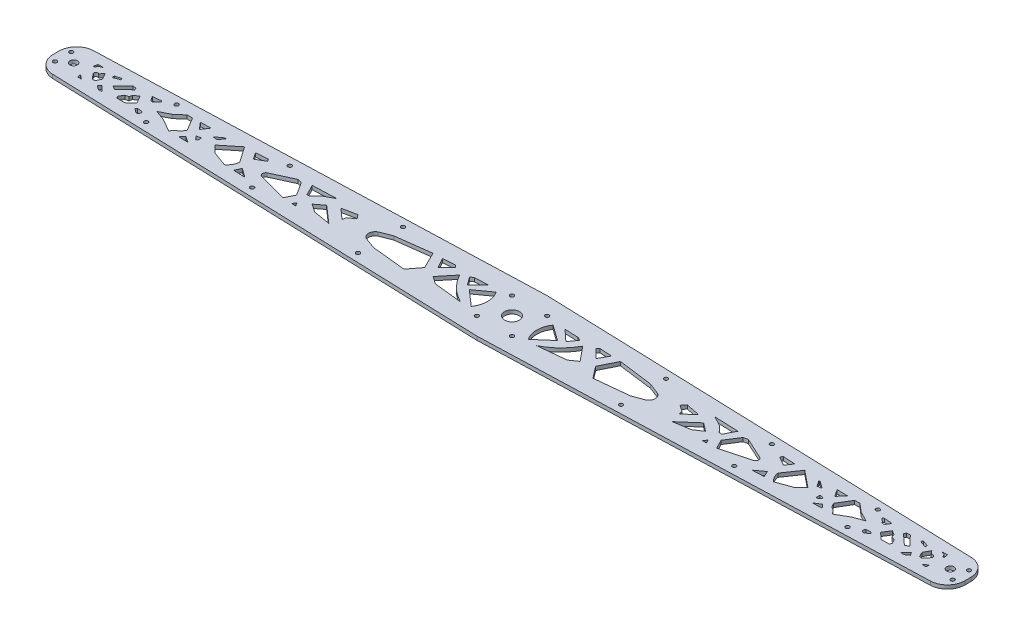
from build123d import *

# Parameters (mm, degrees)
BOSS_EXTRUDE1_DEPTH = 3.18
SKETCH3_R           = 6.35
SKETCH3_R_2         = 3.175
SKETCH3_R_3         = 1.65
CUT_EXTRUDE1_DEPTH  = 4.18
CUT_EXTRUDE3_DEPTH  = 4.18


with BuildPart() as part:
    # Sketch2 → Boss-Extrude1 (new body)
    with BuildSketch(Plane(origin=(0, 0, 0), x_dir=(1, 0, 0), z_dir=(0, 1, 0))):
        with BuildLine():
            Line((-375, 17.5), (0, 30))
            Line((0, 30), (375, 17.5))
            Line((375, 17.5), (375.499722453, 17.483342585))
            ThreePointArc((375.499722453, 17.483342585), (385.781832794, 12.920095592), (390, 2.49166898))
            Line((390, 2.49166898), (390, -2.49166898))
            ThreePointArc((390, -2.49166898), (385.781832794, -12.920095592), (375.499722453, -17.483342585))
            Line((375.499722453, -17.483342585), (375, -17.5))
            Line((375, -17.5), (0, -30))
            Line((0, -30), (-375, -17.5))
            Line((-375, -17.5), (-375.499722453, -17.483342585))
            ThreePointArc((-375.499722453, -17.483342585), (-385.781832794, -12.920095592), (-390, -2.49166898))
            Line((-390, -2.49166898), (-390, 2.49166898))
            ThreePointArc((-390, 2.49166898), (-385.781832794, 12.920095592), (-375.499722453, 17.483342585))
            Line((-375.499722453, 17.483342585), (-375, 17.5))
        make_face()
    extrude(amount=BOSS_EXTRUDE1_DEPTH)

    # Sketch3 → Cut-Extrude1 (cut, through all)
    with BuildSketch(Plane(origin=(0, 3.18, 0), x_dir=(1, 0, 0), z_dir=(0, 1, 0))):
        Circle(SKETCH3_R)
        with Locations((-375, 0)):
            Circle(SKETCH3_R_2)
        with Locations((-206.25, 16.125)):
            Circle(SKETCH3_R_3)
        with Locations((-112.5, -19.25)):
            Circle(SKETCH3_R_3)
        with Locations((375, 0)):
            Circle(SKETCH3_R_2)
        with Locations((-112.5, 19.25)):
            Circle(SKETCH3_R_3)
        with Locations((-206.25, -16.125)):
            Circle(SKETCH3_R_3)
        with Locations((112.5, -19.25)):
            Circle(SKETCH3_R_3)
        with Locations((112.5, 19.25)):
            Circle(SKETCH3_R_3)
        with Locations((206.25, -16.125)):
            Circle(SKETCH3_R_3)
        with Locations((206.25, 16.125)):
            Circle(SKETCH3_R_3)
        with Locations((-384, 7)):
            Circle(SKETCH3_R_3)
        with Locations((-384, -7)):
            Circle(SKETCH3_R_3)
        with Locations((384, -7)):
            Circle(SKETCH3_R_3)
        with Locations((384, 7)):
            Circle(SKETCH3_R_3)
        with Locations((-15, 15)):
            Circle(SKETCH3_R_3)
        with Locations((-15, -15)):
            Circle(SKETCH3_R_3)
        with Locations((15, -15)):
            Circle(SKETCH3_R_3)
        with Locations((15, 15)):
            Circle(SKETCH3_R_3)
        with Locations((-300, 13)):
            Circle(SKETCH3_R_3)
        with Locations((-300, -13)):
            Circle(SKETCH3_R_3)
        with Locations((300, -13)):
            Circle(SKETCH3_R_3)
        with Locations((300, 13)):
            Circle(SKETCH3_R_3)
    extrude(amount=-CUT_EXTRUDE1_DEPTH, mode=Mode.SUBTRACT)

    # Sketch7 → Cut-Extrude3 (cut, through all)
    with BuildSketch(Plane(origin=(0, 3.18, 0), x_dir=(1, 0, 0), z_dir=(0, 1, 0))):
        with BuildLine():
            Line((-24.407137101, -10.442196584), (-37.737976277, 1.176424717))
            Line((-37.737976277, 1.176424717), (-24.407137101, 10.756691403))
            ThreePointArc((-24.407137101, 10.756691403), (-21.114319799, 0.15724741), (-24.407137101, -10.442196584))
        make_face()
        Polygon((-47.032873318, 10.756691403), (-42.100055152, 3.989354084), (-32.560555558, 12.795046017), (-44.311711664, 12.275450641), align=None)
        with BuildLine():
            Line((-62.901056318, -4.620655806), (-52.686453676, 7.824722126))
            ThreePointArc((-52.686453676, 7.824722126), (-44.0876591, -3.407389681), (-32.560555558, -11.606504739))
            Line((-32.560555558, -11.606504739), (-56.443548901, -9.082206385))
            Line((-56.443548901, -9.082206385), (-62.901056318, -4.620655806))
        make_face()
        Polygon((-67.588188675, 4.294041195), (-60.209562693, 11.672667178), (-61.976612281, 13.439716766), (-72.268482179, 12.795046017), align=None)
        with BuildLine():
            Line((-80.185072794, 12.558357188), (-73.149864274, -1.58852951))
            Line((-73.149864274, -1.58852951), (-80.835064886, -11.606504739))
            Line((-80.835064886, -11.606504739), (-109.817065203, -8.62373803))
            Line((-109.817065203, -8.62373803), (-119.45224209, -5.10613377))
            ThreePointArc((-119.45224209, -5.10613377), (-122.572007437, -0.078253768), (-119.45224209, 4.949626234))
            Line((-119.45224209, 4.949626234), (-109.817065203, 8.734874297))
            Line((-109.817065203, 8.734874297), (-80.185072794, 12.558357188))
        make_face()
        Polygon((-152.955538995, 6.592573199), (-140.860134128, 9.080280583), (-138.15796921, 5.606068547), (-143.519407538, 1.960290484), (-144.13133888, -1.25234906), align=None)
        Polygon((-161.233599773, 2.670112069), (-146.907836561, -9.834873837), (-161.233599773, -7.51873248), (-168.353589872, -2.714883738), align=None)
        Polygon((-177.489480783, -11.035836023), (-174.015268746, -11.035836023), (-175.752374765, -8.162105079), align=None)
        Polygon((-161.729723103, 11.950195027), (-182.143953394, 11.194112424), (-177.489480783, 2.121121183), (-175.112385183, 2.121121183), (-170.399470289, 7.287685639), align=None)
        with BuildLine():
            Line((-185.506248388, -10.442196584), (-181.633562672, -2.714883738))
            Line((-181.633562672, -2.714883738), (-188.948635691, 8.734874297))
            Line((-188.948635691, 8.734874297), (-192.659508912, 9.552536436))
            Line((-192.659508912, 9.552536436), (-210.807795066, 1.176424717))
            ThreePointArc((-210.807795066, 1.176424717), (-212.203585831, -1.601696145), (-210.076287764, -3.869027245))
            Line((-210.076287764, -3.869027245), (-185.506248388, -10.442196584))
        make_face()
        Polygon((-224.660331091, -6.041638234), (-216.978750516, -11.606504739), (-226.878924239, -11.194499739), align=None)
        Polygon((-230.656176232, 11.194112424), (-226.73221345, 5.473034029), (-219.038926813, 9.938233057), (-220.316522778, 11.800948653), align=None)
        with BuildLine():
            Line((-234.968138526, -11.035836023), (-247.825130983, -6.366302871))
            Line((-247.825130983, -6.366302871), (-253.58861036, -0.454469849))
            Line((-253.58861036, -0.454469849), (-239.606204771, 10.869590855))
            Line((-239.606204771, 10.869590855), (-230.288910191, -2.714883738))
            ThreePointArc((-230.288910191, -2.714883738), (-231.784913115, -7.349758663), (-234.968138526, -11.035836023))
        make_face()
        Polygon((-260.557495016, 4.815029739), (-254.49352909, 9.209486059), (-253.434447052, 9.040421587), (-256.719541898, 4.294041195), align=None)
        Polygon((-264.619650899, -4.506994477), (-264.619650899, -1.050329246), (-268.373663676, -1.849450778), (-266.143557076, -4.506994477), align=None)
        Polygon((-267.017015494, -10.082260979), (-272.443608223, -6.662764191), (-275.191119735, -9.834873837), align=None)
        Polygon((-271.850180843, 4.294041195), (-276.772538387, 10.159850602), (-267.877645437, 10.319369489), align=None)
        Polygon((-283.259508539, 9.938233057), (-287.796156437, 9.938233057), (-294.696972958, 3.989354084), (-303.418838283, -0.454469849), (-294.217749588, -3.869027245), (-283.962369481, -9.834873837), (-281.182873937, -6.366302871), (-278.658964191, -5.10613377), (-276.486484916, -1.343368188), align=None)
        with BuildLine():
            Line((-311.562944086, -10.218378698), (-314.957545036, -7.729004668))
            Line((-314.957545036, -7.729004668), (-313.73343136, -6.504890992))
            Line((-313.73343136, -6.504890992), (-309.608476872, -6.957504452))
            ThreePointArc((-309.608476872, -6.957504452), (-309.336871978, -9.336456765), (-311.562944086, -10.218378698))
        make_face()
        with BuildLine():
            Line((-314.744216601, 6.0973281), (-316.436971173, 8.734874297))
            Line((-316.436971173, 8.734874297), (-309.436426843, 9.353728844))
            Line((-309.436426843, 9.353728844), (-308.030579826, 8.49300618))
            Line((-308.030579826, 8.49300618), (-310.928346127, 5.968219701))
            ThreePointArc((-310.928346127, 5.968219701), (-312.882927532, 4.654120501), (-314.744216601, 6.0973281))
        make_face()
        Polygon((-330.278555961, -7.729004668), (-323.545509256, -7.729004668), (-318.046854447, -2.714883738), (-321.899653395, 3.533809703), (-325.72299749, 1.176424717), (-326.320647591, -1.343368188), (-329.118975695, -2.189279996), (-331.400730412, -6.041638234), align=None)
        Polygon((-340.833722487, -0.454469849), (-337.904787965, -2.189279996), (-328.817412912, 6.0973281), (-329.642657105, 7.824722126), (-332.635122308, 8.172130767), align=None)
        with BuildLine():
            Line((-347.457132436, 5.606068547), (-342.281198017, 7.564900967))
            ThreePointArc((-342.281198017, 7.564900967), (-342.33920639, 8.453268789), (-343.008395415, 9.040421587))
            Line((-343.008395415, 9.040421587), (-347.692402183, 7.564900967))
            ThreePointArc((-347.692402183, 7.564900967), (-347.827661429, 6.555110369), (-347.457132436, 5.606068547))
        make_face()
        Polygon((-341.727270653, -9.082206385), (-346.334724493, -4.620655806), (-347.864811775, -6.957504452), (-344.581141315, -9.294402896), align=None)
        Polygon((-362.832168153, -8.834890265), (-363.310108547, -5.789080129), (-359.619964107, -8.834890265), align=None)
        Polygon((-358.508438564, 9.209486059), (-361.670517076, 7.939062578), (-362.832168153, 5.803865744), (-364.03277573, 5.803865744), (-363.310108547, 9.209486059), align=None)
        with BuildLine():
            Line((-353.551022177, 5.606068547), (-350.631830893, 0.15724741))
            Line((-350.631830893, 0.15724741), (-352.479131627, -3.672925161))
            ThreePointArc((-352.479131627, -3.672925161), (-354.049655649, -4.203221543), (-355.535160002, -3.467669524))
            Line((-355.535160002, -3.467669524), (-358.294708012, -0.078253768))
            ThreePointArc((-358.294708012, -0.078253768), (-358.481510141, 2.297941823), (-356.10531455, 2.484743952))
            Line((-356.10531455, 2.484743952), (-353.551022177, 5.606068547))
        make_face()
        with BuildLine():
            Line((239.606204771, 10.869590855), (230.288910191, -2.714883738))
            ThreePointArc((230.288910191, -2.714883738), (231.784913115, -7.349758663), (234.968138526, -11.035836023))
            Line((234.968138526, -11.035836023), (247.825130983, -6.366302871))
            Line((247.825130983, -6.366302871), (253.58861036, -0.454469849))
            Line((253.58861036, -0.454469849), (239.606204771, 10.869590855))
        make_face()
        Polygon((47.032873318, 10.756691403), (44.311711664, 12.275450641), (32.560555558, 12.795046017), (42.100055152, 3.989354084), align=None)
        with BuildLine():
            Line((37.737976277, 1.176424717), (24.407137101, 10.756691403))
            ThreePointArc((24.407137101, 10.756691403), (21.114319799, 0.15724741), (24.407137101, -10.442196584))
            Line((24.407137101, -10.442196584), (37.737976277, 1.176424717))
        make_face()
        with BuildLine():
            Line((32.560555558, -11.606504739), (56.443548901, -9.082206385))
            Line((56.443548901, -9.082206385), (62.901056318, -4.620655806))
            Line((62.901056318, -4.620655806), (52.686453676, 7.824722126))
            ThreePointArc((52.686453676, 7.824722126), (44.0876591, -3.407389681), (32.560555558, -11.606504739))
        make_face()
        Polygon((61.976612281, 13.439716766), (72.268482179, 12.795046017), (67.588188675, 4.294041195), (60.209562693, 11.672667178), align=None)
        with BuildLine():
            Line((109.817065203, 8.734874297), (119.45224209, 4.949626234))
            ThreePointArc((119.45224209, 4.949626234), (122.572007437, -0.078253768), (119.45224209, -5.10613377))
            Line((119.45224209, -5.10613377), (109.817065203, -8.62373803))
            Line((109.817065203, -8.62373803), (80.835064886, -11.606504739))
            Line((80.835064886, -11.606504739), (73.149864274, -1.58852951))
            Line((73.149864274, -1.58852951), (80.185072794, 12.558357188))
            Line((80.185072794, 12.558357188), (109.817065203, 8.734874297))
        make_face()
        Polygon((143.519407538, 1.960290484), (144.13133888, -1.25234906), (152.955538995, 6.592573199), (140.860134128, 9.080280583), (138.15796921, 5.606068547), align=None)
        Polygon((175.112385183, 2.121121183), (170.399470289, 7.287685639), (161.729723103, 11.950195027), (182.143953394, 11.194112424), (177.489480783, 2.121121183), align=None)
        Polygon((161.233599773, -7.51873248), (168.353589872, -2.714883738), (161.233599773, 2.670112069), (146.907836561, -9.834873837), align=None)
        Polygon((174.015268746, -11.035836023), (175.752374765, -8.162105079), (177.489480783, -11.035836023), align=None)
        with BuildLine():
            Line((192.659508912, 9.552536436), (210.807795066, 1.176424717))
            ThreePointArc((210.807795066, 1.176424717), (212.203585831, -1.601696145), (210.076287764, -3.869027245))
            Line((210.076287764, -3.869027245), (185.506248388, -10.442196584))
            Line((185.506248388, -10.442196584), (181.633562672, -2.714883738))
            Line((181.633562672, -2.714883738), (188.948635691, 8.734874297))
            Line((188.948635691, 8.734874297), (192.659508912, 9.552536436))
        make_face()
        Polygon((219.038926813, 9.938233057), (220.316522778, 11.800948653), (230.656176232, 11.194112424), (226.73221345, 5.473034029), align=None)
        Polygon((216.978750516, -11.606504739), (226.878924239, -11.194499739), (224.660331091, -6.041638234), align=None)
        Polygon((276.772538387, 10.159850602), (267.877645437, 10.319369489), (271.850180843, 4.294041195), align=None)
        Polygon((253.434447052, 9.040421587), (256.719541898, 4.294041195), (260.557495016, 4.815029739), (254.49352909, 9.209486059), align=None)
        Polygon((268.373663676, -1.849450778), (266.143557076, -4.506994477), (264.619650899, -4.506994477), (264.619650899, -1.050329246), align=None)
        Polygon((272.443608223, -6.662764191), (275.191119735, -9.834873837), (267.017015494, -10.082260979), align=None)
        Polygon((278.658964191, -5.10613377), (276.486484916, -1.343368188), (283.259508539, 9.938233057), (287.796156437, 9.938233057), (294.696972958, 3.989354084), (303.418838283, -0.454469849), (294.217749588, -3.869027245), (283.962369481, -9.834873837), (281.182873937, -6.366302871), align=None)
        with BuildLine():
            Line((313.73343136, -6.504890992), (309.608476872, -6.957504452))
            ThreePointArc((309.608476872, -6.957504452), (309.336871978, -9.336456765), (311.562944086, -10.218378698))
            Line((311.562944086, -10.218378698), (314.957545036, -7.729004668))
            Line((314.957545036, -7.729004668), (313.73343136, -6.504890992))
        make_face()
        with BuildLine():
            Line((314.744216601, 6.0973281), (316.436971173, 8.734874297))
            Line((316.436971173, 8.734874297), (309.436426843, 9.353728844))
            Line((309.436426843, 9.353728844), (308.030579826, 8.49300618))
            Line((308.030579826, 8.49300618), (310.928346127, 5.968219701))
            ThreePointArc((310.928346127, 5.968219701), (312.882927532, 4.654120501), (314.744216601, 6.0973281))
        make_face()
        Polygon((329.118975695, -2.189279996), (331.400730412, -6.041638234), (330.278555961, -7.729004668), (323.545509256, -7.729004668), (318.046854447, -2.714883738), (321.899653395, 3.533809703), (325.72299749, 1.176424717), (326.320647591, -1.343368188), align=None)
        Polygon((329.642657105, 7.824722126), (332.635122308, 8.172130767), (340.833722487, -0.454469849), (337.904787965, -2.189279996), (328.817412912, 6.0973281), align=None)
        with BuildLine():
            Line((347.457132436, 5.606068547), (342.281198017, 7.564900967))
            ThreePointArc((342.281198017, 7.564900967), (342.33920639, 8.453268789), (343.008395415, 9.040421587))
            Line((343.008395415, 9.040421587), (347.692402183, 7.564900967))
            ThreePointArc((347.692402183, 7.564900967), (347.827661429, 6.555110369), (347.457132436, 5.606068547))
        make_face()
        Polygon((347.864811775, -6.957504452), (344.581141315, -9.294402896), (341.727270653, -9.082206385), (346.334724493, -4.620655806), align=None)
        Polygon((363.310108547, -5.789080129), (359.619964107, -8.834890265), (362.832168153, -8.834890265), align=None)
        with BuildLine():
            Line((355.535160002, -3.467669524), (358.294708012, -0.078253768))
            ThreePointArc((358.294708012, -0.078253768), (358.481510141, 2.297941823), (356.10531455, 2.484743952))
            Line((356.10531455, 2.484743952), (353.551022177, 5.606068547))
            Line((353.551022177, 5.606068547), (350.631830893, 0.15724741))
            Line((350.631830893, 0.15724741), (352.479131627, -3.672925161))
            ThreePointArc((352.479131627, -3.672925161), (354.049655649, -4.203221543), (355.535160002, -3.467669524))
        make_face()
        Polygon((364.03277573, 5.803865744), (363.310108547, 9.209486059), (358.508438564, 9.209486059), (361.670517076, 7.939062578), (362.832168153, 5.803865744), align=None)
    extrude(amount=-CUT_EXTRUDE3_DEPTH, mode=Mode.SUBTRACT)


solid = part.part
